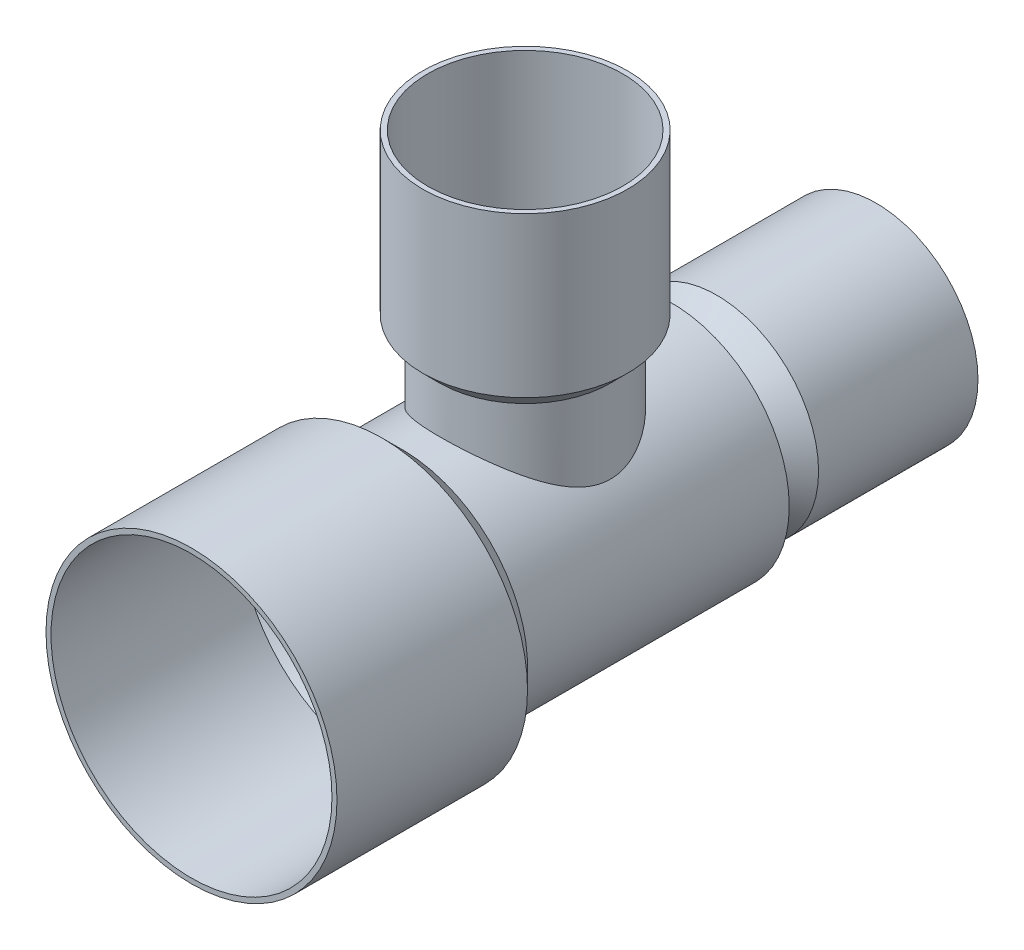
from build123d import *

# Parameters (mm, degrees)
SKETCH2_R          = 16.51
SKETCH3_R          = 20.6375
EXTRUDE1_DEPTH     = 27.686
SKETCH4_R          = 20.6375
EXTRUDE2_DEPTH     = 2.54
EXTRUDE2_TAPER     = 45
SKETCH9_R          = 16.51
SKETCH9_R_2        = 14.224
CUT_EXTRUDE4_DEPTH = 23.114
SKETCH10_R         = 16.51
SKETCH10_R_2       = 14.224
CUT_EXTRUDE5_DEPTH = 3.81
CUT_EXTRUDE5_DRAFT = 45
SKETCH11_OUTSIDE_W = 79.734
SKETCH11_OUTSIDE_H = 79.734
SKETCH11_OUTSIDE_R = 10.414
CUT_EXTRUDE6_DEPTH = 3.81
CUT_EXTRUDE6_DRAFT = -60
SHELL3_T           = 0.7366


with BuildPart() as part:
    # Sweep1: sweep along a path in Sketch1
    with BuildLine(Plane(origin=(0, 0, 0), x_dir=(0, 0, -1), z_dir=(1, 0, 0))) as sweep1_path:
        Line((51.562, 0), (-49.022, 0))
    # Sketch2 → Sweep1 (sweep)
    with BuildSketch(Plane.XY.offset(49.022)):
        Circle(SKETCH2_R)
    sweep(path=sweep1_path.line)

    # Sketch3 → Extrude1 (add)
    with BuildSketch(Plane.XY.offset(49.022)):
        Circle(SKETCH3_R)
    extrude(amount=-EXTRUDE1_DEPTH)

    # Sketch4 → Extrude2 (add)
    with BuildSketch(Plane(origin=(0, 0, 21.336), x_dir=(-1, 0, 0), z_dir=(0, 0, -1))):
        with Locations(Location((0, 0, 0), (0, 0, 180))):
            Circle(SKETCH4_R)
    extrude(amount=EXTRUDE2_DEPTH, taper=EXTRUDE2_TAPER)

    # Sketch9 → Cut-Extrude4 (cut)
    with BuildSketch(Plane(origin=(0, 0, -51.562), x_dir=(-1, 0, 0), z_dir=(0, 0, -1))):
        Circle(SKETCH9_R)
        Circle(SKETCH9_R_2, mode=Mode.SUBTRACT)
    extrude(amount=-CUT_EXTRUDE4_DEPTH, mode=Mode.SUBTRACT)


with BuildPart() as cut_extrude5_tool:
    # Sketch10 → Cut-Extrude5 (with draft: the straight prism first)
    with BuildSketch(Plane(origin=(0, 0, -28.448), x_dir=(-1, 0, 0), z_dir=(0, 0, -1))):
        Circle(SKETCH10_R)
        Circle(SKETCH10_R_2, mode=Mode.SUBTRACT)
    extrude(amount=-CUT_EXTRUDE5_DEPTH)
    # Cut-Extrude5: the draft: its side faces are tilted about the plane it starts from
    cut_extrude5_sides = [cut_extrude5_tool.faces().sort_by_distance(p)[0] for p in [
        (16.51, 0, -26.543),
        (14.224, 0, -26.543),
    ]]
    draft(cut_extrude5_sides, Plane(origin=(0, 0, -28.448), x_dir=(-1, 0, 0), z_dir=(0, 0, -1)), CUT_EXTRUDE5_DRAFT)


with BuildPart() as part_1:
    add(part.part)

    # Cut-Extrude5: cut by cut_extrude5_tool
    add(cut_extrude5_tool.part, mode=Mode.SUBTRACT)


with BuildPart() as cut_extrude6_tool:
    # Sketch11 outside → Cut-Extrude6 (with draft: the straight prism first)
    with BuildSketch(Plane(origin=(0, 0, -24.638), x_dir=(-1, 0, 0), z_dir=(0, 0, -1))):
        Rectangle(SKETCH11_OUTSIDE_W, SKETCH11_OUTSIDE_H)
        Circle(SKETCH11_OUTSIDE_R, mode=Mode.SUBTRACT)
    extrude(amount=-CUT_EXTRUDE6_DEPTH)
    # Cut-Extrude6: the draft: its side faces are tilted about the plane it starts from
    cut_extrude6_sides = [cut_extrude6_tool.faces().sort_by_distance(p)[0] for p in [
        (0, -39.867, -22.733),
        (-39.867, 0, -22.733),
        (0, 39.867, -22.733),
        (39.867, 0, -22.733),
        (10.414, 0, -22.733),
    ]]
    draft(cut_extrude6_sides, Plane(origin=(0, 0, -24.638), x_dir=(-1, 0, 0), z_dir=(0, 0, -1)), CUT_EXTRUDE6_DRAFT)


with BuildPart() as part_2:
    add(part_1.part)

    # Cut-Extrude6: cut by cut_extrude6_tool
    add(cut_extrude6_tool.part, mode=Mode.SUBTRACT)


with BuildPart() as body_2:
    # Sketch5 → Revolve1 (revolve)
    with BuildSketch(Plane(origin=(0, 0, 0), x_dir=(0, 0, -1), z_dir=(1, 0, 0)), mode=Mode.PRIVATE) as revolve1_sk:
        Polygon((11.7856, 24.384), (14.3256, 26.924), (14.3256, 50.038), (0, 50.038), (0, 0), (11.7856, 0), align=None)
    revolve(revolve1_sk.sketch.rotate(Axis((0, 50.038, 0), (0, -1, 0)), 180), axis=Axis((0, 50.038, 0), (0, -1, 0)))

    # Combine1: union part
    add(part_2.part)

    # Shell3
    shell3_openings = [body_2.faces().sort_by_distance(p)[0] for p in [
        (0, 0, -51.562),
        (0, 0, 49.022),
        (0, 50.038, 0),
    ]]
    offset(amount=SHELL3_T, openings=shell3_openings, kind=Kind.INTERSECTION)


solid = body_2.part
